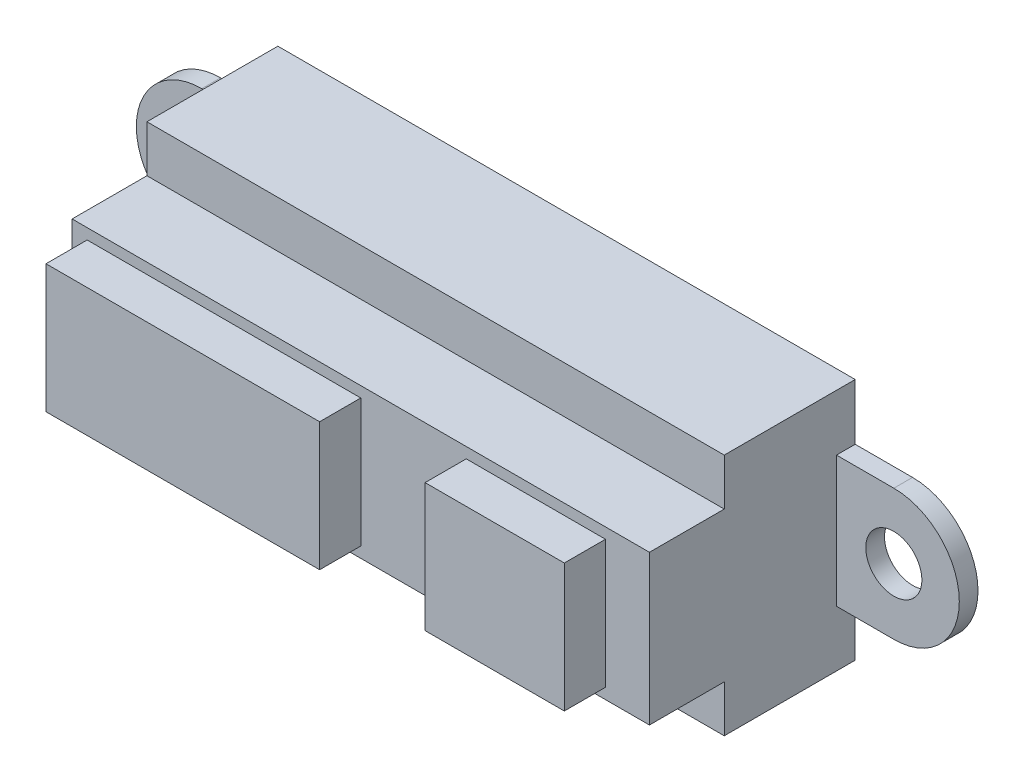
from build123d import *

# Parameters (mm, degrees)
SKETCH_1_W                = 37
SKETCH_1_H                = 7
EXTRUDE_1_DEPTH           = 1
SKETCH_3_W                = 30.866999712
SKETCH_3_H                = 13
EXTRUDE_2_DEPTH           = 7
SKETCH_4_W                = 30.866999712
SKETCH_4_H                = 8
EXTRUDE_3_DEPTH           = 11
SKETCH_5_W                = 14.630132385
SKETCH_5_H                = 6.854419706
SKETCH_5_W_2              = 7.444047208
EXTRUDE_4_DEPTH           = 13.2
SKETCH_6_R                = 3.5
EXTRUDE_5_DEPTH           = 1
HOLE_WIZARD_3_0_3_1_D     = 3
HOLE_WIZARD_3_0_3_1_DEPTH = 8.5
HOLE_WIZARD_3_0_3_1_TIP   = 0.901290929


with BuildPart() as part:
    # 草图1 → 凸台-拉伸1 (new body)
    with BuildSketch(Plane.XY):
        Rectangle(SKETCH_1_W, SKETCH_1_H)
    extrude(amount=EXTRUDE_1_DEPTH)

    # 草图3 → 凸台-拉伸2 (add)
    with BuildSketch(Plane.XY):
        Rectangle(SKETCH_3_W, SKETCH_3_H)
    extrude(amount=EXTRUDE_2_DEPTH)

    # 草图4 → 凸台-拉伸3 (add)
    with BuildSketch(Plane.XY):
        Rectangle(SKETCH_4_W, SKETCH_4_H)
    extrude(amount=EXTRUDE_3_DEPTH)

    # 草图5 → 凸台-拉伸4 (add)
    with BuildSketch(Plane.XY):
        with Locations((-7.315066193, 0)):
            Rectangle(SKETCH_5_W, SKETCH_5_H)
        with Locations((9.360336589, 0)):
            Rectangle(SKETCH_5_W_2, SKETCH_5_H)
    extrude(amount=EXTRUDE_4_DEPTH)

    # 草图6 → 凸台-拉伸5 (add)
    with BuildSketch(Plane.XY.offset(1)):
        with Locations((18.5, 0)):
            Circle(SKETCH_6_R)
        with Locations((-18.5, 0)):
            Circle(SKETCH_6_R)
    extrude(amount=-EXTRUDE_5_DEPTH)

    # Ø3.0 (3) 直径孔1
    with Locations(Plane.XY.offset(1)):
        with Locations((-18.5, 0), (18.5, 0)):
            Hole(HOLE_WIZARD_3_0_3_1_D / 2, depth=HOLE_WIZARD_3_0_3_1_DEPTH)
            with Locations((0, 0, -(HOLE_WIZARD_3_0_3_1_DEPTH + HOLE_WIZARD_3_0_3_1_TIP / 2))):  # 118° drill point
                Cone(0, HOLE_WIZARD_3_0_3_1_D / 2, HOLE_WIZARD_3_0_3_1_TIP, mode=Mode.SUBTRACT)


solid = part.part
